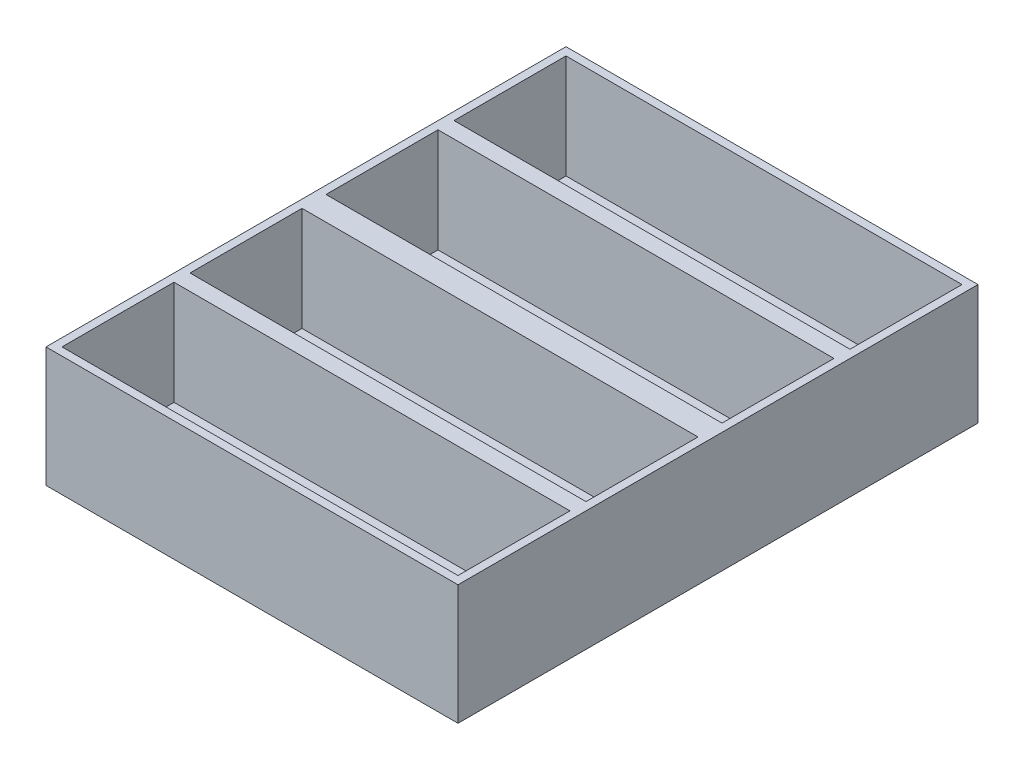
from build123d import *

# Parameters (mm, degrees)
SKETCH1_W           = 51.5
SKETCH1_H           = 65
SKETCH1_R           = 1.5025
BOSS_EXTRUDE1_DEPTH = 15
SKETCH2_W           = 49.5
SKETCH2_H           = 14
CUT_EXTRUDE1_DEPTH  = 13


with BuildPart() as part:
    # Sketch1 → Boss-Extrude1 (new body)
    with BuildSketch(Plane(origin=(0, 0, 0), x_dir=(1, 0, 0), z_dir=(0, 1, 0))):
        Rectangle(SKETCH1_W, SKETCH1_H)
        with Locations((-7.5, -13)):
            Circle(SKETCH1_R, mode=Mode.SUBTRACT)
        with Locations((7.5, -13)):
            Circle(SKETCH1_R, mode=Mode.SUBTRACT)
        with Locations((7.5, 22)):
            Circle(SKETCH1_R, mode=Mode.SUBTRACT)
        with Locations((-7.5, 22)):
            Circle(SKETCH1_R, mode=Mode.SUBTRACT)
    extrude(amount=BOSS_EXTRUDE1_DEPTH)

    # Sketch2 → Cut-Extrude1 (cut)
    with BuildSketch(Plane(origin=(0, 15, 0), x_dir=(1, 0, 0), z_dir=(0, 1, 0))):
        with Locations((0, -8.5)):
            Rectangle(SKETCH2_W, SKETCH2_H)
        with Locations((0, -24.5)):
            Rectangle(SKETCH2_W, SKETCH2_H)
        with Locations((0, 24.5)):
            Rectangle(SKETCH2_W, SKETCH2_H)
        with Locations((0, 8.5)):
            Rectangle(SKETCH2_W, SKETCH2_H)
    extrude(amount=-CUT_EXTRUDE1_DEPTH, mode=Mode.SUBTRACT)


solid = part.part
